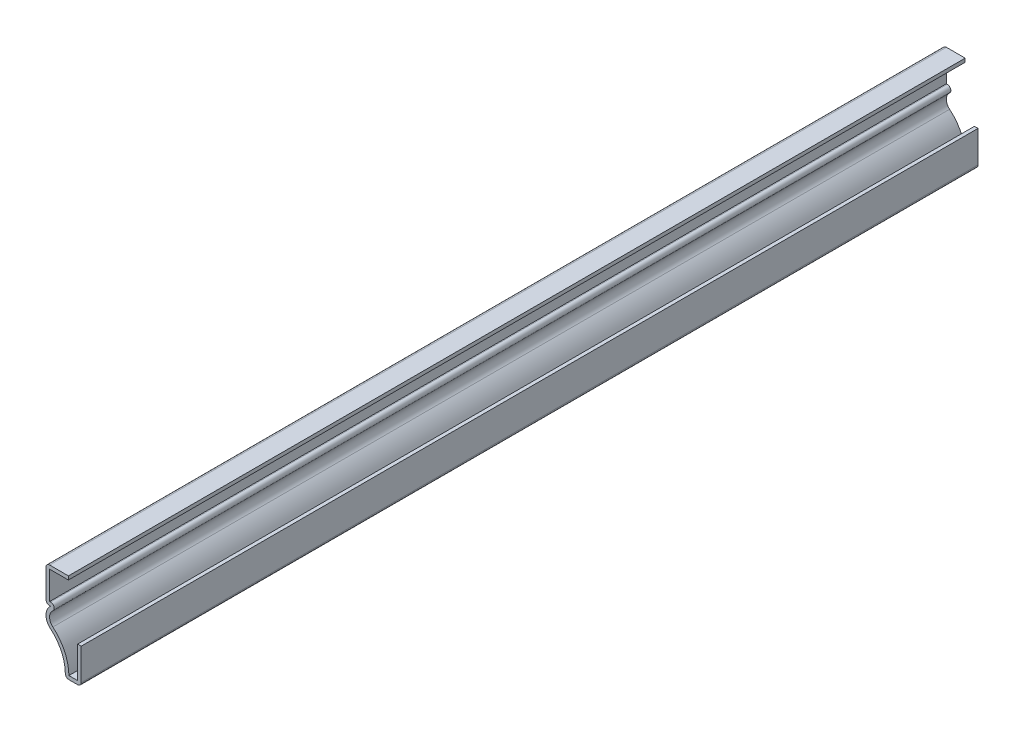
from build123d import *

# Parameters (mm, degrees)
BOSS_EXTRUDE1_DEPTH = 222.25
FILLET1_R           = 0.889


with BuildPart() as part:
    # Sketch1 → Boss-Extrude1 (new body)
    with BuildSketch(Plane.XY):
        with BuildLine():
            Line((0, 8.73125), (0, 0))
            Line((0, 0), (-3.96875, 0))
            ThreePointArc((-3.96875, 0), (-4.748467779, 4.757288038), (-7.604139417, 8.641215018))
            ThreePointArc((-7.604139417, 8.641215018), (-8.73125, 11.067482509), (-7.604139417, 13.49375))
            Line((-7.604139417, 13.49375), (-8.73125, 13.49375))
            Line((-8.73125, 13.49375), (-8.73125, 22.225))
            Line((-8.73125, 22.225), (-3.175, 22.225))
            Line((-3.175, 22.225), (-3.175, 21.336))
            Line((-3.175, 21.336), (-7.84225, 21.336))
            Line((-7.84225, 21.336), (-7.84225, 14.38275))
            Line((-7.84225, 14.38275), (-7.604139417, 14.38275))
            ThreePointArc((-7.604139417, 14.38275), (-6.769194058, 13.799015865), (-7.03073038, 12.814395103))
            ThreePointArc((-7.03073038, 12.814395103), (-7.84225, 11.067482509), (-7.03073038, 9.320569916))
            ThreePointArc((-7.03073038, 9.320569916), (-4.123486495, 5.538022334), (-3.052821022, 0.889))
            Line((-3.052821022, 0.889), (-0.889, 0.889))
            Line((-0.889, 0.889), (-0.889, 8.73125))
            Line((-0.889, 8.73125), (0, 8.73125))
        make_face()
    extrude(amount=-BOSS_EXTRUDE1_DEPTH)

    # Fillet1
    fillet1_edges = [part.edges().sort_by_distance(p)[0] for p in [
        (0, 0, -111.125),
        (-3.96875, 0, -111.125),
        (-8.73125, 13.49375, -111.125),
        (-8.73125, 22.225, -111.125),
    ]]
    fillet(fillet1_edges, radius=FILLET1_R)


solid = part.part
